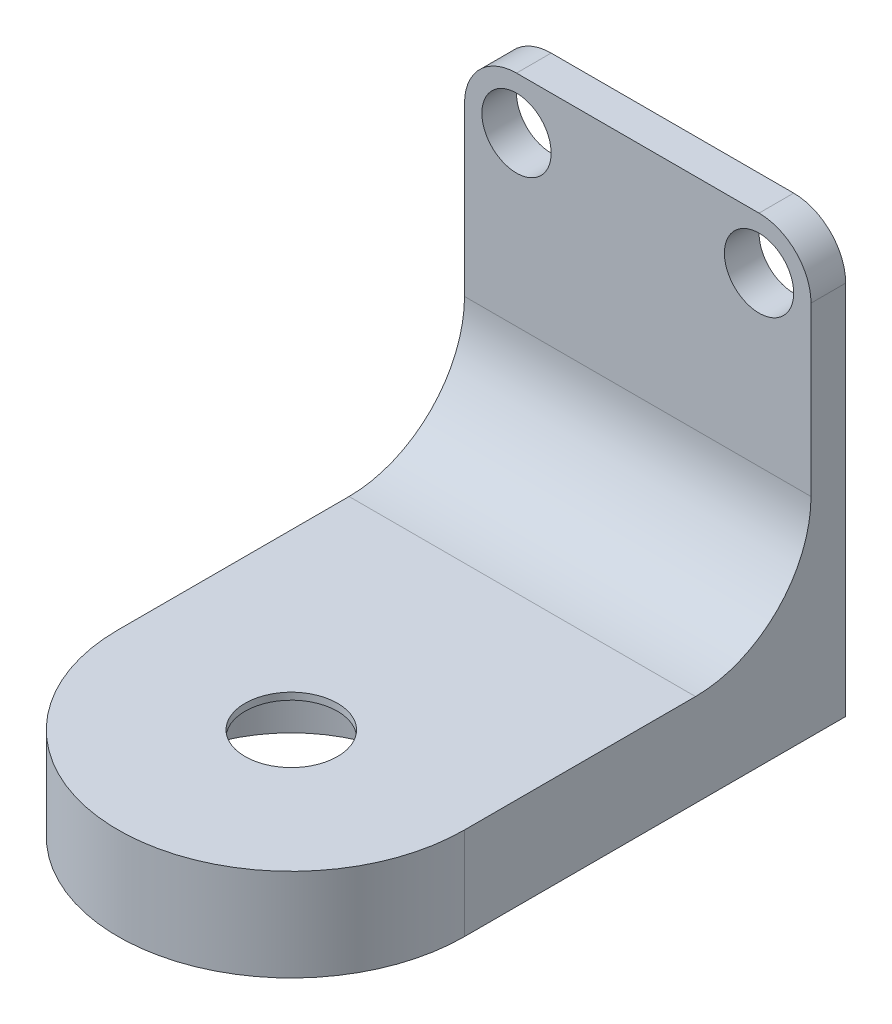
from build123d import *

# Parameters (mm, degrees)
SKETCH_1_R          = 11
EXTRUDE_1_DEPTH     = 8
SKETCH_2_W          = 30
SKETCH_2_H          = 8
SKETCH_2_R          = 3
EXTRUDE_2_DEPTH     = 3
FILLET_1_R          = 10
EXTRUDE_START       = 8
SKETCH_1_2_R        = 11
EXTRUDE_3_DEPTH     = 1
SKETCH_3_R          = 4
CUT_EXTRUDE_1_DEPTH = 31
SKETCH_4_R          = 6.25
CUT_EXTRUDE_2_DEPTH = 0.4


with BuildPart() as part:
    # 草圖1 → 填料-伸長1 (new body)
    with BuildSketch(Plane(origin=(0, 0, 0), x_dir=(1, 0, 0), z_dir=(0, 1, 0))):
        with BuildLine():
            Line((-15, 0), (-15, 30))
            Line((-15, 30), (15, 30))
            Line((15, 30), (15, 0))
            ThreePointArc((15, 0), (0, -15), (-15, 0))
        make_face()
        Circle(SKETCH_1_R, mode=Mode.SUBTRACT)
    extrude(amount=EXTRUDE_1_DEPTH)

    # 草圖2 → 填料-伸長2 (add)
    with BuildSketch(Plane(origin=(0, 0, -30), x_dir=(-1, 0, 0), z_dir=(0, 0, -1))):
        with Locations((0, 4)):
            Rectangle(SKETCH_2_W, SKETCH_2_H)
        with Locations((-10.5, 4)):
            Circle(SKETCH_2_R, mode=Mode.SUBTRACT)
        with Locations((10.5, 4)):
            Circle(SKETCH_2_R, mode=Mode.SUBTRACT)
        with BuildLine():
            Line((15, 32.5), (15, 8))
            Line((15, 8), (-15, 8))
            Line((-15, 8), (-15, 32.5))
            ThreePointArc((-15, 32.5), (-13.681980515, 35.681980515), (-10.5, 37))
            Line((-10.5, 37), (10.5, 37))
            ThreePointArc((10.5, 37), (13.681980515, 35.681980515), (15, 32.5))
        make_face()
        with Locations((10.5, 32.5)):
            Circle(SKETCH_2_R, mode=Mode.SUBTRACT)
        with Locations((-10.5, 32.5)):
            Circle(SKETCH_2_R, mode=Mode.SUBTRACT)
    extrude(amount=EXTRUDE_2_DEPTH)

    # 圓角1
    fillet_1_edges = [part.edges().sort_by_distance(p)[0] for p in [
        (0, 8, -30),
    ]]
    fillet(fillet_1_edges, radius=FILLET_1_R)

    # 草圖1<2> → 填料-伸長3 (add)
    with BuildSketch(Plane(origin=(0, 0, 0), x_dir=(1, 0, 0), z_dir=(0, 1, 0)).offset(EXTRUDE_START)):
        Circle(SKETCH_1_2_R)
    extrude(amount=-EXTRUDE_3_DEPTH)

    # 草圖3 → 除料-伸長1 (cut, through all)
    with BuildSketch(Plane(origin=(0, 7, 0), x_dir=(-1, 0, 0), z_dir=(0, -1, 0))):
        Circle(SKETCH_3_R)
    extrude(amount=-CUT_EXTRUDE_1_DEPTH, mode=Mode.SUBTRACT)

    # 草圖4 → 除料-伸長2 (cut)
    with BuildSketch(Plane(origin=(0, 7, 0), x_dir=(-1, 0, 0), z_dir=(0, -1, 0))):
        Circle(SKETCH_4_R)
    extrude(amount=-CUT_EXTRUDE_2_DEPTH, mode=Mode.SUBTRACT)


solid = part.part
